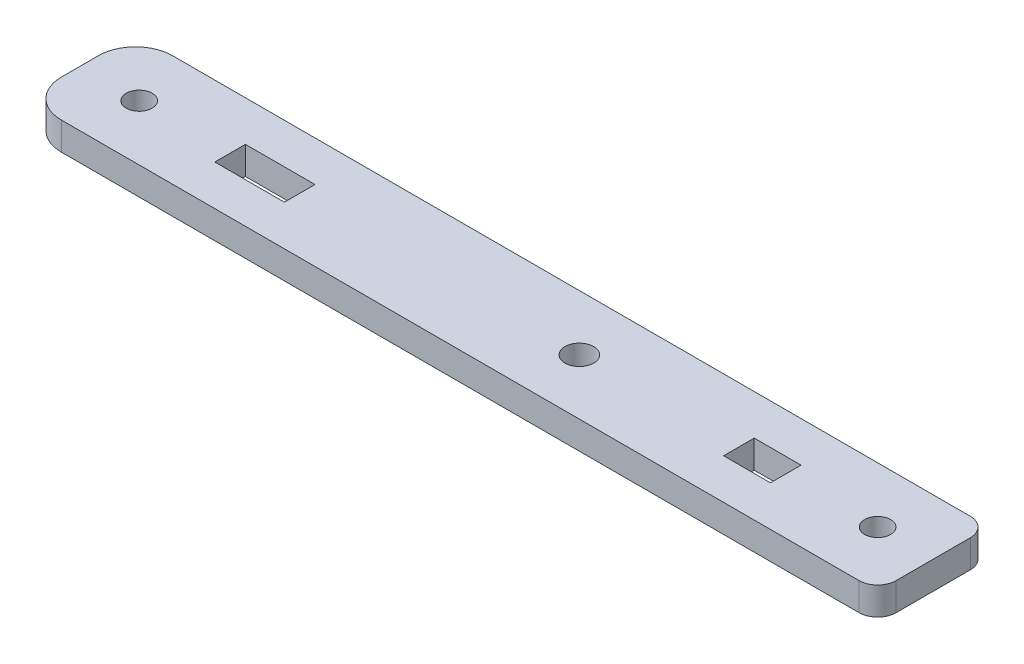
from build123d import *

# Parameters (mm, degrees)
SKETCH1_W           = 92
SKETCH1_H           = 12
BOSS_EXTRUDE1_DEPTH = 3
FILLET1_R           = 4
FILLET2_R           = 2
SKETCH2_R           = 1.4
SKETCH2_R_2         = 1.55
SKETCH2_W           = 7.5
SKETCH2_H           = 3
SKETCH2_W_2         = 5.05
CUT_EXTRUDE1_DEPTH  = 4
SKETCH3_W           = 7.5
SKETCH3_H           = 0.15
SKETCH3_W_2         = 5.05
CUT_EXTRUDE2_DEPTH  = 4


with BuildPart() as part:
    # Sketch1 → Boss-Extrude1 (new body)
    with BuildSketch(Plane(origin=(0, 0, 0), x_dir=(1, 0, 0), z_dir=(0, 1, 0))):
        with Locations((46, 6)):
            Rectangle(SKETCH1_W, SKETCH1_H)
    extrude(amount=BOSS_EXTRUDE1_DEPTH)

    # Fillet1
    fillet1_edges = [part.edges().sort_by_distance(p)[0] for p in [
        (0, 1.5, -12),
        (0, 1.5, 0),
    ]]
    fillet(fillet1_edges, radius=FILLET1_R)

    # Fillet2
    fillet2_edges = [part.edges().sort_by_distance(p)[0] for p in [
        (92, 1.5, -12),
        (92, 1.5, 0),
    ]]
    fillet(fillet2_edges, radius=FILLET2_R)

    # Sketch2 → Cut-Extrude1 (cut, through all)
    with BuildSketch(Plane(origin=(0, 3, 0), x_dir=(1, 0, 0), z_dir=(0, 1, 0))):
        with Locations((6.4, 6)):
            Circle(SKETCH2_R)
        with Locations((53.85, 6)):
            Circle(SKETCH2_R_2)
        with Locations((86, 6)):
            Circle(SKETCH2_R)
        with Locations((19.95, 6)):
            Rectangle(SKETCH2_W, SKETCH2_H)
        with Locations((73.575, 6)):
            Rectangle(SKETCH2_W_2, SKETCH2_H)
    extrude(amount=-CUT_EXTRUDE1_DEPTH, mode=Mode.SUBTRACT)

    # Sketch3 → Cut-Extrude2 (cut, through all)
    with BuildSketch(Plane(origin=(0, 3, 0), x_dir=(1, 0, 0), z_dir=(0, 1, 0))):
        with Locations((19.95, 7.575)):
            Rectangle(SKETCH3_W, SKETCH3_H)
        with Locations((19.95, 4.425)):
            Rectangle(SKETCH3_W, SKETCH3_H)
        with Locations((73.575, 7.575)):
            Rectangle(SKETCH3_W_2, SKETCH3_H)
        with Locations((73.575, 4.425)):
            Rectangle(SKETCH3_W_2, SKETCH3_H)
    extrude(amount=-CUT_EXTRUDE2_DEPTH, mode=Mode.SUBTRACT)


solid = part.part
